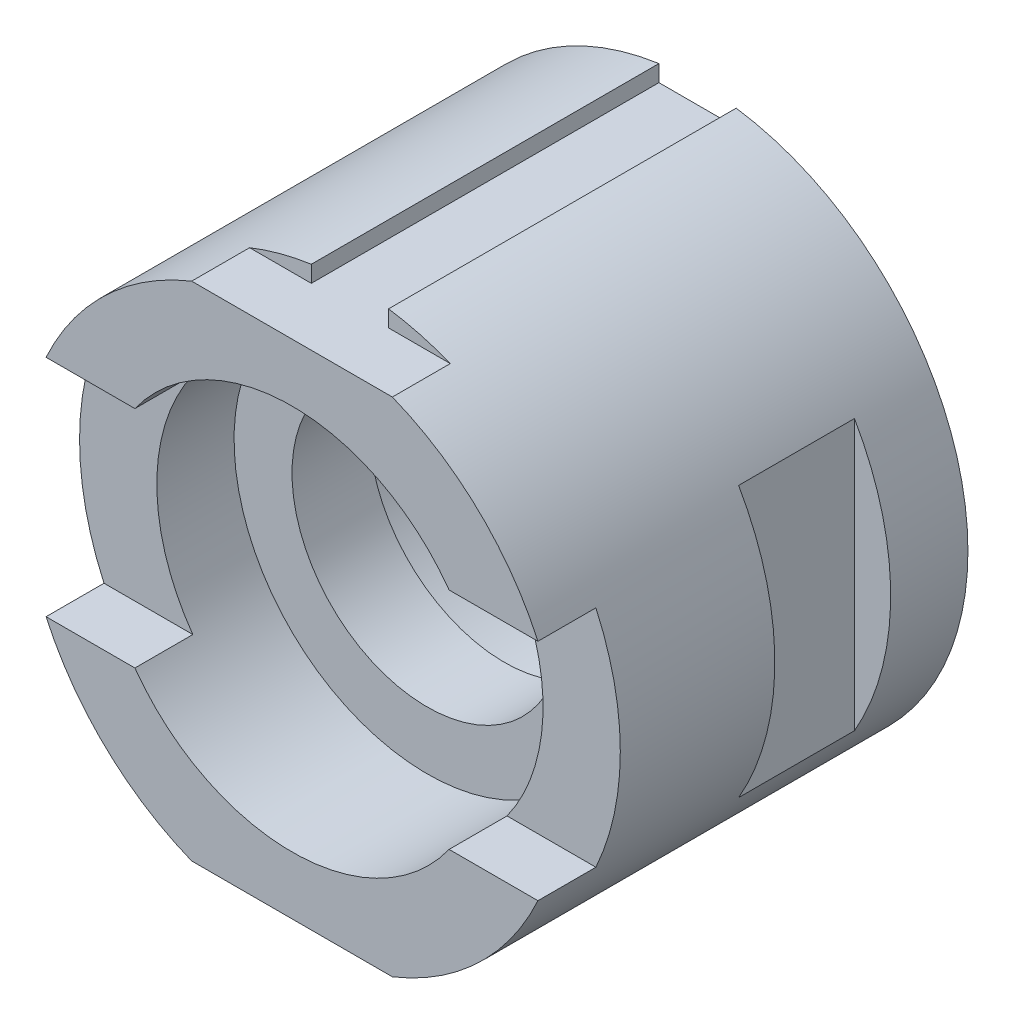
from build123d import *

# Parameters (mm, degrees)
SKETCH1_R                = 35
BOSS_EXTRUDE1_DEPTH      = 10
BOSS_EXTRUDE3_DEPTH      = 15
SKETCH3_R                = 25
CUT_EXTRUDE1_DEPTH       = 58
SKETCH4_R                = 35
BOSS_EXTRUDE5_DEPTH      = 10
SKETCH8_R                = 17.5
CUT_EXTRUDE4_DEPTH       = 201.5
SKETCH9_R                = 35
SKETCH9_R_2              = 25
BOSS_EXTRUDE7_DEPTH      = 10
BOSS_EXTRUDE8_DEPTH      = 7.5
CUT_EXTRUDE5_DEPTH       = 7.5
CUT_EXTRUDE15_DEPTH      = 91
CUT_EXTRUDE16_DEPTH      = 91
SKETCH21_W               = 4.689110868
SKETCH21_H               = 15
CUT_EXTRUDE17_DEPTH      = 40
CUT_EXTRUDE17_DEPTH_BACK = 30


with BuildPart() as part:
    # Sketch1 → Boss-Extrude1 (new body)
    with BuildSketch(Plane.XY):
        Circle(SKETCH1_R)
    extrude(amount=BOSS_EXTRUDE1_DEPTH)

    # Sketch2 → Boss-Extrude3 (add)
    with BuildSketch(Plane.XY.offset(10)):
        with BuildLine():
            Line((-30.310889132, 17.5), (-30.310889132, -17.5))
            ThreePointArc((-30.310889132, -17.5), (35, 0), (-30.310889132, 17.5))
        make_face()
    extrude(amount=BOSS_EXTRUDE3_DEPTH)

    # Sketch3 → Cut-Extrude1 (cut)
    with BuildSketch(Plane.XY.offset(25)):
        Circle(SKETCH3_R)
    extrude(amount=-CUT_EXTRUDE1_DEPTH, mode=Mode.SUBTRACT)

    # Sketch4 → Boss-Extrude5 (add)
    with BuildSketch(Plane.XY.offset(25)):
        Circle(SKETCH4_R)
    extrude(amount=BOSS_EXTRUDE5_DEPTH)

    # Sketch8 → Cut-Extrude4 (cut)
    with BuildSketch(Plane.XY.offset(35)):
        Circle(SKETCH8_R)
    extrude(amount=-CUT_EXTRUDE4_DEPTH, mode=Mode.SUBTRACT)

    # Sketch9 → Boss-Extrude7 (add)
    with BuildSketch(Plane.XY.offset(35)):
        Circle(SKETCH9_R)
        Circle(SKETCH9_R_2, mode=Mode.SUBTRACT)
    extrude(amount=BOSS_EXTRUDE7_DEPTH)

    # Sketch10 → Boss-Extrude8 (add)
    with BuildSketch(Plane.XY.offset(45)):
        with BuildLine():
            Line((-31.836956522, 14.539883061), (-20.336956522, 14.539883061))
            ThreePointArc((-20.336956522, 14.539883061), (0, 25), (20.336956522, 14.539883061))
            Line((20.336956522, 14.539883061), (31.836956522, 14.539883061))
            ThreePointArc((31.836956522, 14.539883061), (0, 35), (-31.836956522, 14.539883061))
        make_face()
        with BuildLine():
            Line((-31.836956522, -14.539883061), (-20.336956522, -14.539883061))
            ThreePointArc((-20.336956522, -14.539883061), (0, -25), (20.336956522, -14.539883061))
            Line((20.336956522, -14.539883061), (31.836956522, -14.539883061))
            ThreePointArc((31.836956522, -14.539883061), (0, -35), (-31.836956522, -14.539883061))
        make_face()
    extrude(amount=BOSS_EXTRUDE8_DEPTH)

    # Sketch11 → Cut-Extrude5 (cut)
    with BuildSketch(Plane.XY.offset(52.5)):
        with BuildLine():
            Line((-12.990381057, -32.5), (12.990381057, -32.5))
            ThreePointArc((12.990381057, -32.5), (0, -35), (-12.990381057, -32.5))
        make_face()
        with BuildLine():
            Line((-12.990381057, 32.5), (12.990381057, 32.5))
            ThreePointArc((12.990381057, 32.5), (0, 35), (-12.990381057, 32.5))
        make_face()
    extrude(amount=-CUT_EXTRUDE5_DEPTH, mode=Mode.SUBTRACT)

    # Sketch19 → Cut-Extrude15 (cut)
    with BuildSketch(Plane.XY.offset(45)):
        with BuildLine():
            Line((-5, 34.641016151), (-5, 32.5))
            Line((-5, 32.5), (5, 32.5))
            Line((5, 32.5), (5, 34.641016151))
            ThreePointArc((5, 34.641016151), (0, 35), (-5, 34.641016151))
        make_face()
    extrude(amount=-CUT_EXTRUDE15_DEPTH, mode=Mode.SUBTRACT)

    # Sketch20 → Cut-Extrude16 (cut)
    with BuildSketch(Plane.XY.offset(45)):
        with BuildLine():
            Line((-5, -34.641016151), (-5, -32.5))
            Line((-5, -32.5), (5, -32.5))
            Line((5, -32.5), (5, -34.641016151))
            ThreePointArc((5, -34.641016151), (0, -35), (-5, -34.641016151))
        make_face()
    extrude(amount=-CUT_EXTRUDE16_DEPTH, mode=Mode.SUBTRACT)

    # Sketch21 → Cut-Extrude17 (cut, two sides)
    with BuildSketch(Plane(origin=(0, 0, 0), x_dir=(1, 0, 0), z_dir=(0, 1, 0))) as cut_extrude17_sk:
        with Locations((32.655444566, -17.5)):
            Rectangle(SKETCH21_W, SKETCH21_H)
    extrude(amount=CUT_EXTRUDE17_DEPTH, mode=Mode.SUBTRACT)
    extrude(cut_extrude17_sk.sketch, amount=-CUT_EXTRUDE17_DEPTH_BACK, mode=Mode.SUBTRACT)


solid = part.part
